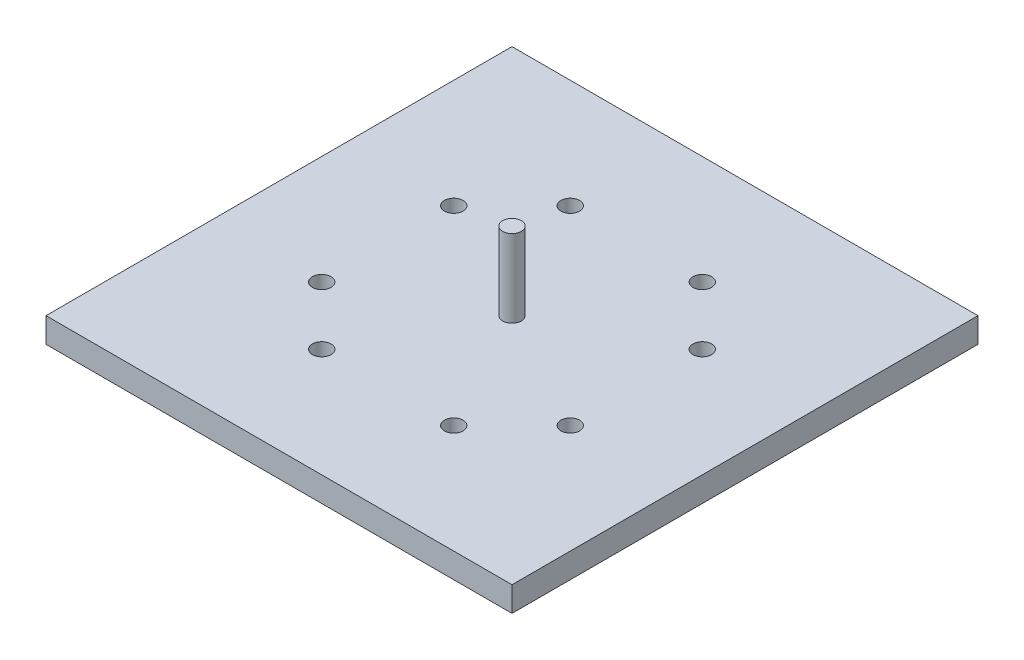
from build123d import *

# Parameters (mm, degrees)
SKETCH1_W           = 30
SKETCH1_H           = 30
BOSS_EXTRUDE1_DEPTH = 1.6
SKETCH2_R           = 0.6
CUT_EXTRUDE1_DEPTH  = 1.6
CIRPATTERN1_COUNT   = 2
CIRPATTERN1_ANGLE   = 90
SKETCH4_R           = 0.6
BOSS_EXTRUDE2_DEPTH = 5


with BuildPart() as part:
    # Sketch1 → Boss-Extrude1 (new body)
    with BuildSketch(Plane(origin=(0, 0, 0), x_dir=(1, 0, 0), z_dir=(0, 1, 0))):
        with Locations((15, 15)):
            Rectangle(SKETCH1_W, SKETCH1_H)
    extrude(amount=BOSS_EXTRUDE1_DEPTH)

    # Sketch2 → Cut-Extrude1 (cut)
    with BuildSketch(Plane(origin=(0, 1.6, 0), x_dir=(1, 0, 0), z_dir=(0, 1, 0))):
        with Locations((19.25, 7)):
            Circle(SKETCH2_R)
        with Locations((10.75, 7)):
            Circle(SKETCH2_R)
        with Locations((19.25, 23)):
            Circle(SKETCH2_R)
        with Locations((10.75, 23)):
            Circle(SKETCH2_R)
    cut_extrude1 = extrude(amount=-CUT_EXTRUDE1_DEPTH, mode=Mode.SUBTRACT)

    # CirPattern1: Cut-Extrude1 ×2 about axis
    cirpattern1_axis = Axis((15, 0, -15), (0, 1, 0))
    for i in range(1, CIRPATTERN1_COUNT):
        add(cut_extrude1.rotate(cirpattern1_axis, i * CIRPATTERN1_ANGLE / (CIRPATTERN1_COUNT - 1)), mode=Mode.SUBTRACT)

    # Sketch4 → Boss-Extrude2 (add)
    with BuildSketch(Plane(origin=(0, 1.6, 0), x_dir=(1, 0, 0), z_dir=(0, 1, 0))):
        with Locations((15, 15)):
            Circle(SKETCH4_R)
    extrude(amount=BOSS_EXTRUDE2_DEPTH)


solid = part.part
